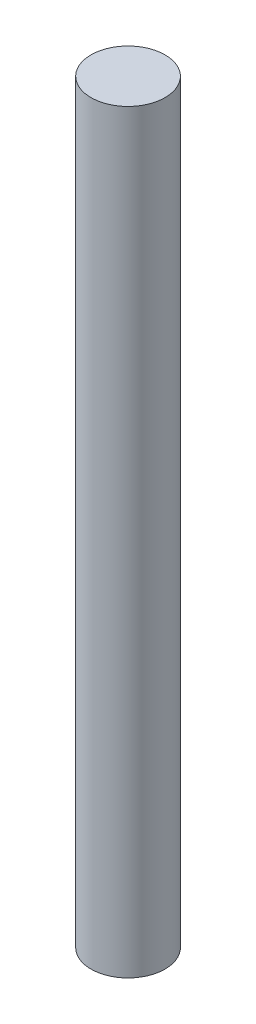
from build123d import *

# Parameters (mm, degrees)
SKETCH1_W = 4
SKETCH1_H = 81.5


with BuildPart() as part:
    # Sketch1 → Revolve1 (revolve)
    with BuildSketch(Plane.XY):
        with Locations((2, 0.75)):
            Rectangle(SKETCH1_W, SKETCH1_H)
    revolve(axis=Axis((0, 41.5, 0), (0, -1, 0)))


solid = part.part
